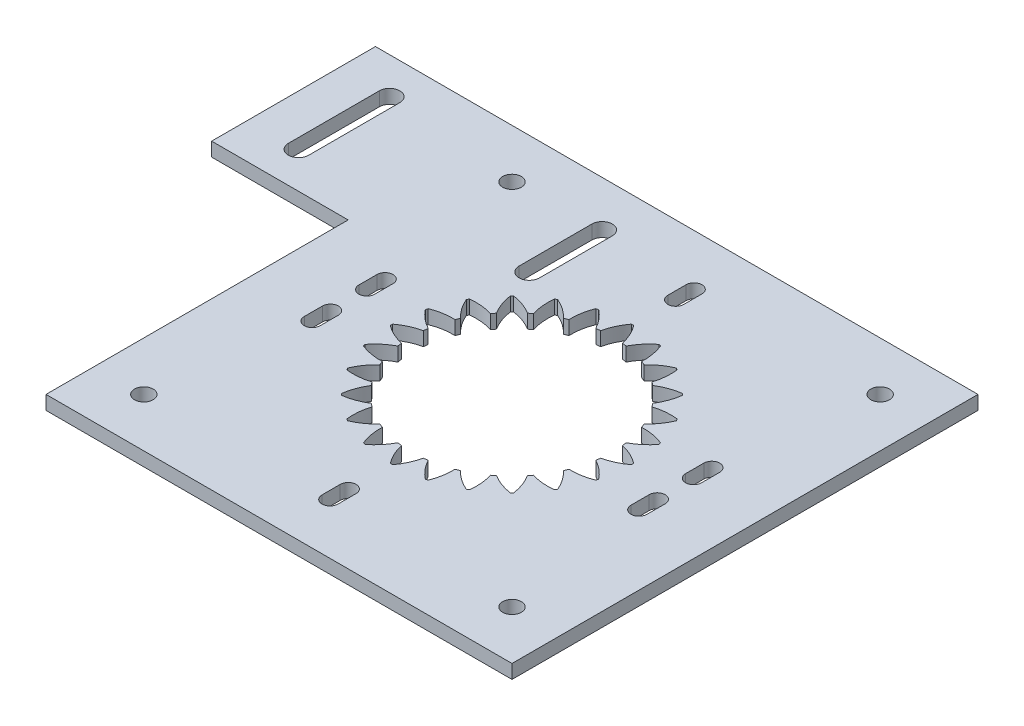
from build123d import *

# Parameters (mm, degrees)
BOSS_EXTRUDE1_DEPTH  = 3.05
CUT_EXTRUDE6_DEPTH   = 10
SKETCH3_R            = 2.05
CUT_EXTRUDE2_DEPTH   = 10
CIRPATTERN1_COUNT    = 4
CUT_EXTRUDE3_DEPTH   = 3.05
CUT_EXTRUDE4_DEPTH   = 10
MIRROR2_COPY_1_DEPTH = 10
CUT_EXTRUDE5_DEPTH   = 10


with BuildPart() as part:
    # Sketch1 → Boss-Extrude1 (new body)
    with BuildSketch(Plane(origin=(0, 0, 0), x_dir=(1, 0, 0), z_dir=(0, 1, 0))):
        Polygon((-51.2, -51.2), (51.2, -51.2), (51.2, 51.2), (-51.2, 51.2), (-81.2, 51.2), (-81.2, 15.2), (-51.2, 15.2), align=None)
    extrude(amount=BOSS_EXTRUDE1_DEPTH)

    # Sketch11 → Cut-Extrude6 (cut)
    with BuildSketch(Plane(origin=(0, 3.05, 0), x_dir=(1, 0, 0), z_dir=(0, 1, 0))):
        with BuildLine():
            ThreePointArc((6.615395458, 25.662025328), (4.76695674, 23.8797306), (3.340018851, 21.744982733))
            ThreePointArc((3.340018851, 21.744982733), (2.871576229, 21.81178695), (2.401805198, 21.868500904))
            ThreePointArc((2.401805198, 21.868500904), (1.576002443, 24.299827703), (0.251839567, 26.499803355))
            ThreePointArc((0.251839567, 26.499803355), (0, 26.501), (-0.251839567, 26.499803355))
            ThreePointArc((-0.251839567, 26.499803355), (-1.576002443, 24.299827703), (-2.401805198, 21.868500904))
            ThreePointArc((-2.401805198, 21.868500904), (-2.871576229, 21.81178695), (-3.340018851, 21.744982733))
            ThreePointArc((-3.340018851, 21.744982733), (-4.76695674, 23.8797306), (-6.615395458, 25.662025328))
            ThreePointArc((-6.615395458, 25.662025328), (-6.858963514, 25.598000322), (-7.101912141, 25.531663576))
            ThreePointArc((-7.101912141, 25.531663576), (-7.811559664, 23.063931705), (-7.979950192, 20.501716878))
            ThreePointArc((-7.979950192, 20.501716878), (-8.419035512, 20.325349715), (-8.854226136, 20.139579925))
            ThreePointArc((-8.854226136, 20.139579925), (-10.785055699, 21.832269319), (-13.031802215, 23.075422684))
            ThreePointArc((-13.031802215, 23.075422684), (-13.2505, 22.950539226), (-13.46800114, 22.823583117))
            ThreePointArc((-13.46800114, 22.823583117), (-13.514772003, 20.256266877), (-13.014274769, 17.737774727))
            ThreePointArc((-13.014274769, 17.737774727), (-13.392751438, 17.453773486), (-13.765032541, 17.161698026))
            ThreePointArc((-13.765032541, 17.161698026), (-16.068170936, 18.296974965), (-18.560113187, 18.916268118))
            ThreePointArc((-18.560113187, 18.916268118), (-18.739036808, 18.739036808), (-18.916268118, 18.560113187))
            ThreePointArc((-18.916268118, 18.560113187), (-18.296974965, 16.068170936), (-17.161698026, 13.765032541))
            ThreePointArc((-17.161698026, 13.765032541), (-17.453773486, 13.392751438), (-17.737774727, 13.014274769))
            ThreePointArc((-17.737774727, 13.014274769), (-20.256266877, 13.514772003), (-22.823583117, 13.46800114))
            ThreePointArc((-22.823583117, 13.46800114), (-22.950539226, 13.2505), (-23.075422684, 13.031802215))
            ThreePointArc((-23.075422684, 13.031802215), (-21.832269319, 10.7850557), (-20.139579925, 8.854226136))
            ThreePointArc((-20.139579925, 8.854226136), (-20.325349715, 8.419035512), (-20.501716878, 7.979950192))
            ThreePointArc((-20.501716878, 7.979950192), (-23.063931705, 7.811559664), (-25.531663576, 7.101912141))
            ThreePointArc((-25.531663576, 7.101912141), (-25.598000323, 6.858963514), (-25.662025328, 6.615395458))
            ThreePointArc((-25.662025328, 6.615395458), (-23.8797306, 4.76695674), (-21.744982733, 3.340018851))
            ThreePointArc((-21.744982733, 3.340018851), (-21.81178695, 2.871576229), (-21.868500904, 2.401805198))
            ThreePointArc((-21.868500904, 2.401805198), (-24.299827703, 1.576002443), (-26.499803355, 0.251839567))
            ThreePointArc((-26.499803355, 0.251839567), (-26.501, 0), (-26.499803355, -0.251839567))
            ThreePointArc((-26.499803355, -0.251839567), (-24.299827703, -1.576002443), (-21.868500904, -2.401805198))
            ThreePointArc((-21.868500904, -2.401805198), (-21.81178695, -2.871576229), (-21.744982733, -3.340018851))
            ThreePointArc((-21.744982733, -3.340018851), (-23.8797306, -4.76695674), (-25.662025328, -6.615395458))
            ThreePointArc((-25.662025328, -6.615395458), (-25.598000323, -6.858963514), (-25.531663576, -7.101912141))
            ThreePointArc((-25.531663576, -7.101912141), (-23.063931705, -7.811559664), (-20.501716878, -7.979950192))
            ThreePointArc((-20.501716878, -7.979950192), (-20.325349715, -8.419035512), (-20.139579925, -8.854226136))
            ThreePointArc((-20.139579925, -8.854226136), (-21.832269319, -10.7850557), (-23.075422684, -13.031802215))
            ThreePointArc((-23.075422684, -13.031802215), (-22.950539226, -13.2505), (-22.823583117, -13.46800114))
            ThreePointArc((-22.823583117, -13.46800114), (-20.256266877, -13.514772003), (-17.737774727, -13.014274769))
            ThreePointArc((-17.737774727, -13.014274769), (-17.453773486, -13.392751438), (-17.161698026, -13.765032541))
            ThreePointArc((-17.161698026, -13.765032541), (-18.296974965, -16.068170936), (-18.916268118, -18.560113187))
            ThreePointArc((-18.916268118, -18.560113187), (-18.739036808, -18.739036808), (-18.560113187, -18.916268118))
            ThreePointArc((-18.560113187, -18.916268118), (-16.068170936, -18.296974965), (-13.765032541, -17.161698026))
            ThreePointArc((-13.765032541, -17.161698026), (-13.392751438, -17.453773487), (-13.014274769, -17.737774727))
            ThreePointArc((-13.014274769, -17.737774727), (-13.514772003, -20.256266877), (-13.46800114, -22.823583117))
            ThreePointArc((-13.46800114, -22.823583117), (-13.2505, -22.950539226), (-13.031802215, -23.075422684))
            ThreePointArc((-13.031802215, -23.075422684), (-10.7850557, -21.832269319), (-8.854226136, -20.139579925))
            ThreePointArc((-8.854226136, -20.139579925), (-8.419035512, -20.325349715), (-7.979950192, -20.501716878))
            ThreePointArc((-7.979950192, -20.501716878), (-7.811559664, -23.063931705), (-7.101912141, -25.531663576))
            ThreePointArc((-7.101912141, -25.531663576), (-6.858963514, -25.598000323), (-6.615395458, -25.662025328))
            ThreePointArc((-6.615395458, -25.662025328), (-4.76695674, -23.8797306), (-3.340018851, -21.744982733))
            ThreePointArc((-3.340018851, -21.744982733), (-2.871576229, -21.81178695), (-2.401805198, -21.868500904))
            ThreePointArc((-2.401805198, -21.868500904), (-1.576002443, -24.299827703), (-0.251839567, -26.499803355))
            ThreePointArc((-0.251839567, -26.499803355), (0, -26.501), (0.251839567, -26.499803355))
            ThreePointArc((0.251839567, -26.499803355), (1.576002443, -24.299827703), (2.401805198, -21.868500904))
            ThreePointArc((2.401805198, -21.868500904), (2.871576229, -21.81178695), (3.340018851, -21.744982733))
            ThreePointArc((3.340018851, -21.744982733), (4.76695674, -23.8797306), (6.615395458, -25.662025328))
            ThreePointArc((6.615395458, -25.662025328), (6.858963514, -25.598000322), (7.101912141, -25.531663576))
            ThreePointArc((7.101912141, -25.531663576), (7.811559664, -23.063931705), (7.979950192, -20.501716878))
            ThreePointArc((7.979950192, -20.501716878), (8.419035512, -20.325349715), (8.854226136, -20.139579925))
            ThreePointArc((8.854226136, -20.139579925), (10.785055699, -21.832269319), (13.031802215, -23.075422684))
            ThreePointArc((13.031802215, -23.075422684), (13.2505, -22.950539226), (13.46800114, -22.823583117))
            ThreePointArc((13.46800114, -22.823583117), (13.514772003, -20.256266877), (13.014274768, -17.737774727))
            ThreePointArc((13.014274768, -17.737774727), (13.392751438, -17.453773486), (13.765032541, -17.161698026))
            ThreePointArc((13.765032541, -17.161698026), (16.068170936, -18.296974964), (18.560113187, -18.916268118))
            ThreePointArc((18.560113187, -18.916268118), (18.739036808, -18.739036808), (18.916268118, -18.560113187))
            ThreePointArc((18.916268118, -18.560113187), (18.296974964, -16.068170936), (17.161698026, -13.765032541))
            ThreePointArc((17.161698026, -13.765032541), (17.453773486, -13.392751438), (17.737774727, -13.014274769))
            ThreePointArc((17.737774727, -13.014274769), (20.256266877, -13.514772003), (22.823583117, -13.46800114))
            ThreePointArc((22.823583117, -13.46800114), (22.950539226, -13.2505), (23.075422684, -13.031802215))
            ThreePointArc((23.075422684, -13.031802215), (21.832269319, -10.785055699), (20.139579925, -8.854226136))
            ThreePointArc((20.139579925, -8.854226136), (20.325349715, -8.419035512), (20.501716878, -7.979950192))
            ThreePointArc((20.501716878, -7.979950192), (23.063931705, -7.811559664), (25.531663576, -7.101912141))
            ThreePointArc((25.531663576, -7.101912141), (25.598000323, -6.858963514), (25.662025328, -6.615395458))
            ThreePointArc((25.662025328, -6.615395458), (23.8797306, -4.76695674), (21.744982733, -3.340018851))
            ThreePointArc((21.744982733, -3.340018851), (21.81178695, -2.871576229), (21.868500904, -2.401805198))
            ThreePointArc((21.868500904, -2.401805198), (24.299827703, -1.576002443), (26.499803355, -0.251839567))
            ThreePointArc((26.499803355, -0.251839567), (26.501, 0), (26.499803355, 0.251839567))
            ThreePointArc((26.499803355, 0.251839567), (24.299827703, 1.576002443), (21.868500904, 2.401805198))
            ThreePointArc((21.868500904, 2.401805198), (21.81178695, 2.871576229), (21.744982733, 3.340018851))
            ThreePointArc((21.744982733, 3.340018851), (23.8797306, 4.76695674), (25.662025328, 6.615395458))
            ThreePointArc((25.662025328, 6.615395458), (25.598000322, 6.858963514), (25.531663576, 7.101912141))
            ThreePointArc((25.531663576, 7.101912141), (23.063931705, 7.811559664), (20.501716878, 7.979950192))
            ThreePointArc((20.501716878, 7.979950192), (20.325349715, 8.419035512), (20.139579925, 8.854226136))
            ThreePointArc((20.139579925, 8.854226136), (21.832269319, 10.785055699), (23.075422684, 13.031802215))
            ThreePointArc((23.075422684, 13.031802215), (22.950539226, 13.2505), (22.823583117, 13.46800114))
            ThreePointArc((22.823583117, 13.46800114), (20.256266877, 13.514772003), (17.737774727, 13.014274768))
            ThreePointArc((17.737774727, 13.014274768), (17.453773486, 13.392751438), (17.161698026, 13.765032541))
            ThreePointArc((17.161698026, 13.765032541), (18.296974964, 16.068170936), (18.916268118, 18.560113187))
            ThreePointArc((18.916268118, 18.560113187), (18.739036808, 18.739036808), (18.560113187, 18.916268118))
            ThreePointArc((18.560113187, 18.916268118), (16.068170936, 18.296974964), (13.765032541, 17.161698026))
            ThreePointArc((13.765032541, 17.161698026), (13.392751438, 17.453773486), (13.014274769, 17.737774727))
            ThreePointArc((13.014274769, 17.737774727), (13.514772003, 20.256266877), (13.46800114, 22.823583117))
            ThreePointArc((13.46800114, 22.823583117), (13.2505, 22.950539226), (13.031802215, 23.075422684))
            ThreePointArc((13.031802215, 23.075422684), (10.785055699, 21.832269319), (8.854226136, 20.139579925))
            ThreePointArc((8.854226136, 20.139579925), (8.419035512, 20.325349715), (7.979950192, 20.501716878))
            ThreePointArc((7.979950192, 20.501716878), (7.811559664, 23.063931705), (7.101912141, 25.531663576))
            ThreePointArc((7.101912141, 25.531663576), (6.858963514, 25.598000323), (6.615395458, 25.662025328))
        make_face()
    extrude(amount=-CUT_EXTRUDE6_DEPTH, mode=Mode.SUBTRACT)

    # Sketch3 → Cut-Extrude2 (cut)
    with BuildSketch(Plane(origin=(0, 3.05, 0), x_dir=(1, 0, 0), z_dir=(0, 1, 0))):
        with Locations((40.45, 40.45)):
            Circle(SKETCH3_R)
    cut_extrude2 = extrude(amount=-CUT_EXTRUDE2_DEPTH, mode=Mode.SUBTRACT)

    # CirPattern1: Cut-Extrude2 ×4 about axis
    cirpattern1_axis = Axis((0, 0, 0), (0, 1, 0))
    for i in range(1, CIRPATTERN1_COUNT):
        add(cut_extrude2.rotate(cirpattern1_axis, i * 360 / CIRPATTERN1_COUNT), mode=Mode.SUBTRACT)

    # Sketch7 → Cut-Extrude3 (cut)
    with BuildSketch(Plane(origin=(0, 3.05, 0), x_dir=(1, 0, 0), z_dir=(0, 1, 0))):
        with BuildLine():
            Line((-1.75, -40), (-1.75, -36))
            ThreePointArc((-1.75, -36), (0, -34.25), (1.75, -36))
            Line((1.75, -36), (1.75, -40))
            ThreePointArc((1.75, -40), (0, -41.75), (-1.75, -40))
        make_face()
    cut_extrude3 = extrude(amount=-CUT_EXTRUDE3_DEPTH, mode=Mode.SUBTRACT)

    # Sketch9 → Cut-Extrude4 (cut)
    with BuildSketch(Plane(origin=(0, 3.05, 0), x_dir=(1, 0, 0), z_dir=(0, 1, 0))):
        with BuildLine():
            Line((37.65, -4), (37.65, -8))
            ThreePointArc((37.65, -8), (35.9, -9.75), (34.15, -8))
            Line((34.15, -8), (34.15, -4))
            ThreePointArc((34.15, -4), (35.9, -2.25), (37.65, -4))
        make_face()
    cut_extrude4 = extrude(amount=-CUT_EXTRUDE4_DEPTH, mode=Mode.SUBTRACT)

    # Mirror1: Cut-Extrude4 across plane
    add(cut_extrude4.mirror(Plane(origin=(0, 0, 0), x_dir=(0, 0, 1), z_dir=(1, 0, 0))), mode=Mode.SUBTRACT)

    # Mirror2: Cut-Extrude3, Cut-Extrude4 across plane
    add(cut_extrude3.mirror(Plane.XY), mode=Mode.SUBTRACT)
    add(cut_extrude4.mirror(Plane.XY), mode=Mode.SUBTRACT)

    # Mirror2 copy 1 sketch → Mirror2 copy 1 (cut)
    with BuildSketch(Plane(origin=(0, 3.05, 0), x_dir=(-1, 0, 0), z_dir=(0, 1, 0))):
        with BuildLine():
            Line((37.65, -4), (37.65, -8))
            ThreePointArc((37.65, -8), (35.9, -9.75), (34.15, -8))
            Line((34.15, -8), (34.15, -4))
            ThreePointArc((34.15, -4), (35.9, -2.25), (37.65, -4))
        make_face()
    extrude(amount=-MIRROR2_COPY_1_DEPTH, mode=Mode.SUBTRACT)

    # Sketch10 → Cut-Extrude5 (cut)
    with BuildSketch(Plane(origin=(0, 3.05, 0), x_dir=(1, 0, 0), z_dir=(0, 1, 0))):
        with BuildLine():
            Line((-67.85, 43.2), (-67.85, 23.2))
            ThreePointArc((-67.85, 23.2), (-70.1, 20.95), (-72.35, 23.2))
            Line((-72.35, 23.2), (-72.35, 43.2))
            ThreePointArc((-72.35, 43.2), (-70.1, 45.45), (-67.85, 43.2))
        make_face()
        with BuildLine():
            Line((-23.65, 25.2), (-23.65, 41.2))
            ThreePointArc((-23.65, 41.2), (-21.4, 43.45), (-19.15, 41.2))
            Line((-19.15, 41.2), (-19.15, 25.2))
            ThreePointArc((-19.15, 25.2), (-21.4, 22.95), (-23.65, 25.2))
        make_face()
    extrude(amount=-CUT_EXTRUDE5_DEPTH, mode=Mode.SUBTRACT)


solid = part.part
